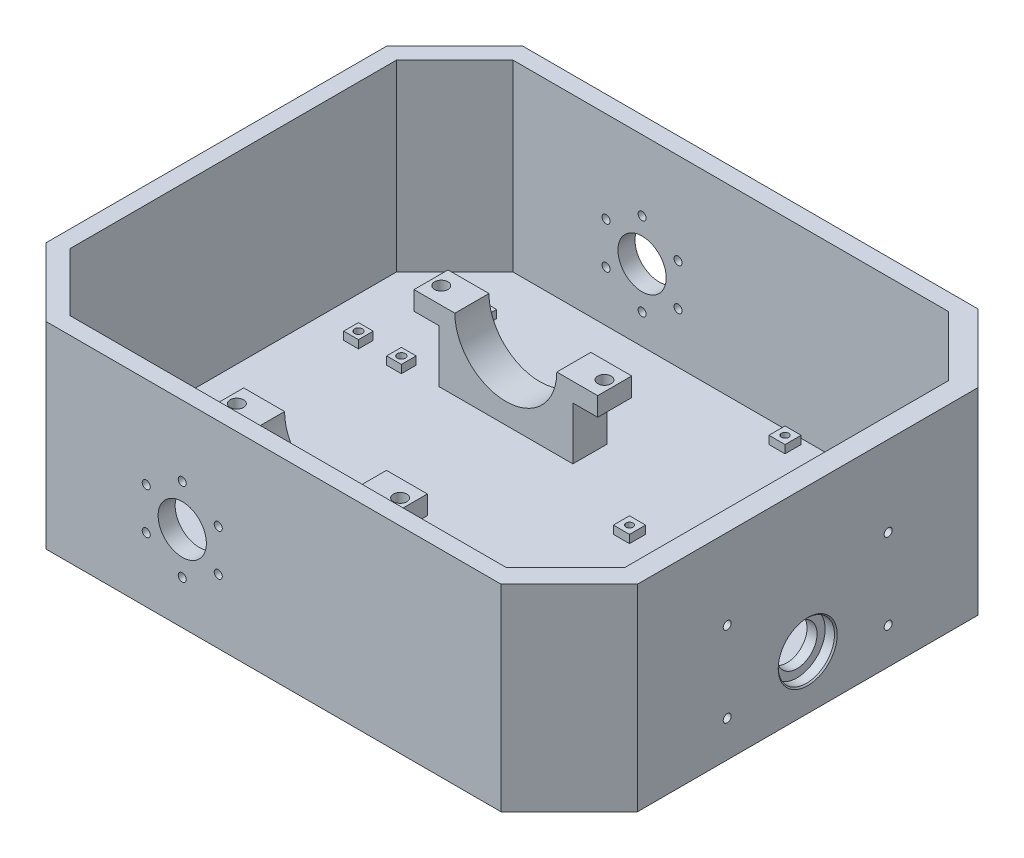
from build123d import *

# Parameters (mm, degrees)
SKETCH2_W               = 190.5
SKETCH2_H               = 177.8
BOSS_EXTRUDE1_DEPTH     = 5.08
CHAMFER1_SIZE           = 25.4
BOSS_EXTRUDE3_DEPTH     = 68.42
SKETCH5_R               = 9
SKETCH5_R_2             = 1.5
CUT_EXTRUDE1_DEPTH      = 231.530019737
SKETCH10_W              = 177.8
SKETCH10_H              = 73.5
BOSS_EXTRUDE6_DEPTH     = 30
CHAMFER3_SIZE           = 25.4
CUT_EXTRUDE2_DEPTH      = 68.42
BOSS_EXTRUDE7_START     = 38.1
BOSS_EXTRUDE7_DEPTH     = 12.7
SKETCH13_W              = 15.24
SKETCH13_H              = 12.7
BOSS_EXTRUDE8_DEPTH     = 7
SKETCH14_R              = 2.5
CUT_EXTRUDE3_DEPTH      = 10
MIRROR4_COPY_1_SKETCH_W = 15.24
MIRROR4_COPY_1_SKETCH_H = 12.7
MIRROR4_COPY_1_DEPTH    = 7
MIRROR4_COPY_2_SKETCH_R = 2.5
MIRROR4_COPY_2_DEPTH    = 10
SKETCH17_W              = 6
SKETCH17_H              = 6
SKETCH17_R              = 1.35
BOSS_EXTRUDE9_DEPTH     = 3
SKETCH18_W              = 5.5
SKETCH18_H              = 5.5
SKETCH18_R              = 1.5
BOSS_EXTRUDE10_DEPTH    = 3
SKETCH19_W              = 6
SKETCH19_H              = 6
SKETCH19_R              = 1.5
BOSS_EXTRUDE11_DEPTH    = 3
SKETCH19_2_R            = 1.5
CUT_EXTRUDE5_DEPTH      = 10
SKETCH17_2_R            = 1.35
CUT_EXTRUDE6_DEPTH      = 10
SKETCH18_2_R            = 1.5
CUT_EXTRUDE7_DEPTH      = 10
SKETCH20_R              = 7.5
CUT_EXTRUDE8_DEPTH      = 10
SKETCH20_3_R            = 10.5
SKETCH20_3_R_2          = 7.5
CUT_EXTRUDE9_DEPTH      = 4
CHAMFER4_SIZE           = 0.5
SKETCH18_3_R            = 1.5
CUT_EXTRUDE10_DEPTH     = 10
SKETCH22_R              = 1.5
CUT_EXTRUDE11_DEPTH     = 10


with BuildPart() as part:
    # Sketch2 → Boss-Extrude1 (new body)
    with BuildSketch(Plane(origin=(0, 0, 0), x_dir=(1, 0, 0), z_dir=(0, 1, 0))):
        with Locations((-31.75, -12.7)):
            Rectangle(SKETCH2_W, SKETCH2_H)
    extrude(amount=BOSS_EXTRUDE1_DEPTH)

    # Chamfer1
    chamfer1_edges = [part.edges().sort_by_distance(p)[0] for p in [
        (-127, 2.54, -76.2),
        (-127, 2.54, 101.6),
    ]]
    chamfer(chamfer1_edges, length=CHAMFER1_SIZE)

    # Sketch4 → Boss-Extrude3 (add)
    with BuildSketch(Plane(origin=(0, 5.08, 0), x_dir=(1, 0, 0), z_dir=(0, 1, 0))):
        Polygon((57.15, 69.85), (-98.969743879, 69.85), (-120.65, 48.169743879), (-120.65, -73.569743879), (-98.969743879, -95.25), (57.15, -95.25), (63.5, -95.25), (63.5, -101.6), (-101.6, -101.6), (-127, -76.2), (-127, 50.8), (-101.6, 76.2), (63.5, 76.2), (63.5, 69.85), align=None)
    extrude(amount=BOSS_EXTRUDE3_DEPTH)

    # Sketch5 → Cut-Extrude1 (cut, through all)
    with BuildSketch(Plane.XY.offset(101.6)):
        with Locations((-50.8, 31.75)):
            Circle(SKETCH5_R)
        with Locations((-50.8, 47.25)):
            Circle(SKETCH5_R_2)
        with Locations((-37.376606241, 39.5)):
            Circle(SKETCH5_R_2)
        with Locations((-37.376606241, 24)):
            Circle(SKETCH5_R_2)
        with Locations((-50.8, 16.25)):
            Circle(SKETCH5_R_2)
        with Locations((-64.223393759, 24)):
            Circle(SKETCH5_R_2)
        with Locations((-64.223393759, 39.5)):
            Circle(SKETCH5_R_2)
    extrude(amount=-CUT_EXTRUDE1_DEPTH, mode=Mode.SUBTRACT)

    # Sketch10 → Boss-Extrude6 (add)
    with BuildSketch(Plane(origin=(63.5, 0, 0), x_dir=(0, 0, -1), z_dir=(1, 0, 0))):
        with Locations((-12.7, 36.75)):
            Rectangle(SKETCH10_W, SKETCH10_H)
    extrude(amount=BOSS_EXTRUDE6_DEPTH)

    # Chamfer3
    chamfer3_edges = [part.edges().sort_by_distance(p)[0] for p in [
        (93.5, 36.75, 101.6),
        (93.5, 36.75, -76.2),
    ]]
    chamfer(chamfer3_edges, length=CHAMFER3_SIZE)

    # Sketch11 → Cut-Extrude2 (cut)
    with BuildSketch(Plane(origin=(0, 73.5, 0), x_dir=(1, 0, 0), z_dir=(0, 1, 0))):
        Polygon((85.757180746, -72.992819254), (85.757180746, 47.592819254), (63.5, 69.85), (63.5, -95.25), align=None)
    extrude(amount=-CUT_EXTRUDE2_DEPTH, mode=Mode.SUBTRACT)

    # Sketch12 → Boss-Extrude7 (add)
    with BuildSketch(Plane(origin=(0, 0, 95.25), x_dir=(-1, 0, 0), z_dir=(0, 0, -1)).offset(BOSS_EXTRUDE7_START)):
        with BuildLine():
            Line((25.8, 5.08), (75.8, 5.08))
            Line((75.8, 5.08), (75.8, 31.75))
            Line((75.8, 31.75), (69.8, 31.75))
            ThreePointArc((69.8, 31.75), (50.8, 12.75), (31.8, 31.75))
            Line((31.8, 31.75), (25.8, 31.75))
            Line((25.8, 31.75), (25.8, 5.08))
        make_face()
    boss_extrude7 = extrude(amount=BOSS_EXTRUDE7_DEPTH)

    # Sketch13 → Boss-Extrude8 (add)
    with BuildSketch(Plane(origin=(0, 31.75, 0), x_dir=(1, 0, 0), z_dir=(0, 1, 0))):
        with Locations((-24.18, -50.8)):
            Rectangle(SKETCH13_W, SKETCH13_H)
    boss_extrude8 = extrude(amount=-BOSS_EXTRUDE8_DEPTH)

    # Sketch14 → Cut-Extrude3 (cut)
    with BuildSketch(Plane(origin=(0, 31.75, 0), x_dir=(1, 0, 0), z_dir=(0, 1, 0))):
        with Locations(Location((-20.37, -50.8, 0), (0, 0, 270))):
            Circle(SKETCH14_R)
    cut_extrude3 = extrude(amount=-CUT_EXTRUDE3_DEPTH, mode=Mode.SUBTRACT)

    # Mirror2: Boss-Extrude8 across plane
    add(boss_extrude8.mirror(Plane.ZY.offset(50.8)))

    # Mirror3: Cut-Extrude3 across plane
    add(cut_extrude3.mirror(Plane.ZY.offset(50.8)), mode=Mode.SUBTRACT)

    # Mirror4: Boss-Extrude7, Boss-Extrude8, Cut-Extrude3 across plane
    add(boss_extrude7.mirror(Plane.XY.offset(12.7)))
    add(boss_extrude8.mirror(Plane.XY.offset(12.7)))
    add(cut_extrude3.mirror(Plane.XY.offset(12.7)), mode=Mode.SUBTRACT)

    # Mirror4 copy 1 sketch → Mirror4 copy 1 (add)
    with BuildSketch(Plane(origin=(-101.6, 31.75, 25.4), x_dir=(-1, 0, 0), z_dir=(0, 1, 0))):
        with Locations((-24.18, -50.8)):
            Rectangle(MIRROR4_COPY_1_SKETCH_W, MIRROR4_COPY_1_SKETCH_H)
    extrude(amount=-MIRROR4_COPY_1_DEPTH)

    # Mirror4 copy 2 sketch → Mirror4 copy 2 (cut)
    with BuildSketch(Plane(origin=(-101.6, 31.75, 25.4), x_dir=(-1, 0, 0), z_dir=(0, 1, 0))):
        with Locations(Location((-20.37, -50.8, 0), (0, 0, 270))):
            Circle(MIRROR4_COPY_2_SKETCH_R)
    extrude(amount=-MIRROR4_COPY_2_DEPTH, mode=Mode.SUBTRACT)

    # Sketch17 → Boss-Extrude9 (add)
    with BuildSketch(Plane(origin=(0, 5.08, 0), x_dir=(1, 0, 0), z_dir=(0, 1, 0))):
        with Locations((7.5, 64.85)):
            Rectangle(SKETCH17_W, SKETCH17_H)
        with Locations(Location((7.5, 64.85, 0), (0, 0, 270))):
            Circle(SKETCH17_R, mode=Mode.SUBTRACT)
        with Locations((56.5, 64.85)):
            Rectangle(SKETCH17_W, SKETCH17_H)
        with Locations(Location((56.5, 64.85, 0), (0, 0, 270))):
            Circle(SKETCH17_R, mode=Mode.SUBTRACT)
        with Locations((7.5, 6.85)):
            Rectangle(SKETCH17_W, SKETCH17_H)
        with Locations(Location((7.5, 6.85, 0), (0, 0, 270))):
            Circle(SKETCH17_R, mode=Mode.SUBTRACT)
        with Locations((56.5, 6.85)):
            Rectangle(SKETCH17_W, SKETCH17_H)
        with Locations(Location((56.5, 6.85, 0), (0, 0, 270))):
            Circle(SKETCH17_R, mode=Mode.SUBTRACT)
    extrude(amount=BOSS_EXTRUDE9_DEPTH)

    # Sketch18 → Boss-Extrude10 (add)
    with BuildSketch(Plane(origin=(0, 5.08, 0), x_dir=(1, 0, 0), z_dir=(0, 1, 0))):
        with Locations((-105.65, 48.95)):
            Rectangle(SKETCH18_W, SKETCH18_H)
        with Locations(Location((-105.65, 48.95, 0), (0, 0, 270))):
            Circle(SKETCH18_R, mode=Mode.SUBTRACT)
        with Locations((-89.65, 18.95)):
            Rectangle(SKETCH18_W, SKETCH18_H)
        with Locations(Location((-89.65, 18.95, 0), (0, 0, 270))):
            Circle(SKETCH18_R, mode=Mode.SUBTRACT)
        with Locations((-105.65, 18.95)):
            Rectangle(SKETCH18_W, SKETCH18_H)
        with Locations(Location((-105.65, 18.95, 0), (0, 0, 270))):
            Circle(SKETCH18_R, mode=Mode.SUBTRACT)
        with Locations((-89.65, 48.95)):
            Rectangle(SKETCH18_W, SKETCH18_H)
        with Locations(Location((-89.65, 48.95, 0), (0, 0, 270))):
            Circle(SKETCH18_R, mode=Mode.SUBTRACT)
    extrude(amount=BOSS_EXTRUDE10_DEPTH)

    # Sketch19 → Boss-Extrude11 (add)
    with BuildSketch(Plane(origin=(0, 5.08, 0), x_dir=(1, 0, 0), z_dir=(0, 1, 0))):
        with Locations((11.057180746, -49.55)):
            Rectangle(SKETCH19_W, SKETCH19_H)
        with Locations(Location((11.057180746, -49.55, 0), (0, 0, 270))):
            Circle(SKETCH19_R, mode=Mode.SUBTRACT)
        with Locations((47.757180746, -49.55)):
            Rectangle(SKETCH19_W, SKETCH19_H)
        with Locations(Location((47.757180746, -49.55, 0), (0, 0, 270))):
            Circle(SKETCH19_R, mode=Mode.SUBTRACT)
        with Locations((11.057180746, -86.25)):
            Rectangle(SKETCH19_W, SKETCH19_H)
        with Locations(Location((11.057180746, -86.25, 0), (0, 0, 270))):
            Circle(SKETCH19_R, mode=Mode.SUBTRACT)
        with Locations((47.757180746, -86.25)):
            Rectangle(SKETCH19_W, SKETCH19_H)
        with Locations(Location((47.757180746, -86.25, 0), (0, 0, 270))):
            Circle(SKETCH19_R, mode=Mode.SUBTRACT)
    extrude(amount=BOSS_EXTRUDE11_DEPTH)

    # Sketch19_2 → Cut-Extrude5 (cut)
    with BuildSketch(Plane(origin=(0, 5.08, 0), x_dir=(1, 0, 0), z_dir=(0, 1, 0))):
        with Locations(Location((11.057180746, -49.55, 0), (0, 0, 270))):
            Circle(SKETCH19_2_R)
        with Locations(Location((47.757180746, -49.55, 0), (0, 0, 270))):
            Circle(SKETCH19_2_R)
        with Locations(Location((47.757180746, -86.25, 0), (0, 0, 270))):
            Circle(SKETCH19_2_R)
        with Locations(Location((11.057180746, -86.25, 0), (0, 0, 270))):
            Circle(SKETCH19_2_R)
    extrude(amount=-CUT_EXTRUDE5_DEPTH, mode=Mode.SUBTRACT)

    # Sketch17_2 → Cut-Extrude6 (cut)
    with BuildSketch(Plane(origin=(0, 5.08, 0), x_dir=(1, 0, 0), z_dir=(0, 1, 0))):
        with Locations(Location((7.5, 64.85, 0), (0, 0, 270))):
            Circle(SKETCH17_2_R)
        with Locations(Location((56.5, 64.85, 0), (0, 0, 270))):
            Circle(SKETCH17_2_R)
        with Locations(Location((56.5, 6.85, 0), (0, 0, 270))):
            Circle(SKETCH17_2_R)
        with Locations(Location((7.5, 6.85, 0), (0, 0, 270))):
            Circle(SKETCH17_2_R)
    extrude(amount=-CUT_EXTRUDE6_DEPTH, mode=Mode.SUBTRACT)

    # Sketch18_2 → Cut-Extrude7 (cut)
    with BuildSketch(Plane(origin=(0, 5.08, 0), x_dir=(1, 0, 0), z_dir=(0, 1, 0))):
        with Locations(Location((-89.65, 18.95, 0), (0, 0, 270))):
            Circle(SKETCH18_2_R)
        with Locations(Location((-105.65, 48.95, 0), (0, 0, 270))):
            Circle(SKETCH18_2_R)
    extrude(amount=-CUT_EXTRUDE7_DEPTH, mode=Mode.SUBTRACT)

    # Sketch20 → Cut-Extrude8 (cut)
    with BuildSketch(Plane(origin=(93.5, 0, 0), x_dir=(0, 0, -1), z_dir=(1, 0, 0))):
        with Locations((-12.7, 20)):
            Circle(SKETCH20_R)
    extrude(amount=-CUT_EXTRUDE8_DEPTH, mode=Mode.SUBTRACT)

    # Sketch20_3 → Cut-Extrude9 (cut)
    with BuildSketch(Plane(origin=(93.5, 0, 0), x_dir=(0, 0, -1), z_dir=(1, 0, 0))):
        with Locations((-12.7, 20)):
            Circle(SKETCH20_3_R)
        with Locations((-12.7, 20)):
            Circle(SKETCH20_3_R_2, mode=Mode.SUBTRACT)
    extrude(amount=-CUT_EXTRUDE9_DEPTH, mode=Mode.SUBTRACT)

    # Chamfer4
    chamfer4_edges = [part.edges().sort_by_distance(p)[0] for p in [
        (93.5, 20, 23.2),
    ]]
    chamfer(chamfer4_edges, length=CHAMFER4_SIZE)

    # Sketch18_3 → Cut-Extrude10 (cut)
    with BuildSketch(Plane(origin=(0, 5.08, 0), x_dir=(1, 0, 0), z_dir=(0, 1, 0))):
        with Locations(Location((-89.65, 48.95, 0), (0, 0, 270))):
            Circle(SKETCH18_3_R)
        with Locations(Location((-105.65, 18.95, 0), (0, 0, 270))):
            Circle(SKETCH18_3_R)
    extrude(amount=-CUT_EXTRUDE10_DEPTH, mode=Mode.SUBTRACT)

    # Sketch22 → Cut-Extrude11 (cut)
    with BuildSketch(Plane(origin=(93.5, 0, 0), x_dir=(0, 0, -1), z_dir=(1, 0, 0))):
        with Locations((-42.7, 43.5)):
            Circle(SKETCH22_R)
        with Locations((17.3, 43.5)):
            Circle(SKETCH22_R)
        with Locations((-42.7, 13.5)):
            Circle(SKETCH22_R)
        with Locations((17.3, 13.5)):
            Circle(SKETCH22_R)
    extrude(amount=-CUT_EXTRUDE11_DEPTH, mode=Mode.SUBTRACT)


solid = part.part
